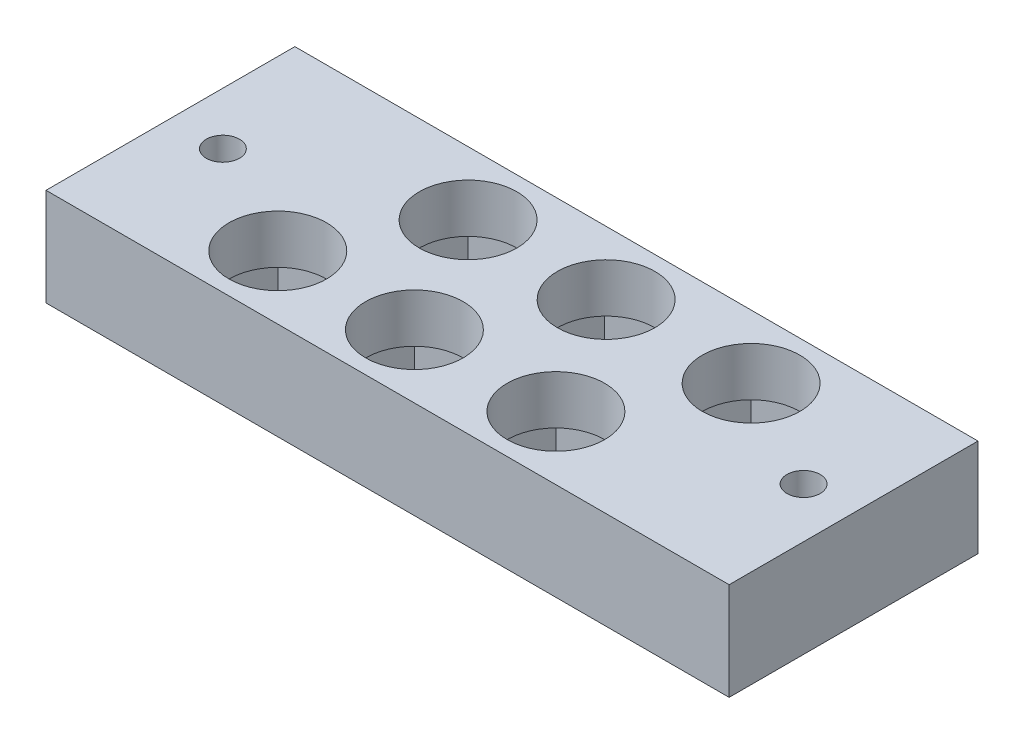
from build123d import *

# Parameters (mm, degrees)
SKETCH1_W           = 70
SKETCH1_H           = 25.5
SKETCH1_W_2         = 12
SKETCH1_H_2         = 12
SKETCH1_R           = 1.7
BOSS_EXTRUDE1_DEPTH = 10
SKETCH1_3_W         = 12
SKETCH1_3_H         = 12
SKETCH1_3_R         = 5
BOSS_EXTRUDE2_DEPTH = 5


with BuildPart() as part:
    # Sketch1 → Boss-Extrude1 (new body)
    with BuildSketch(Plane(origin=(0, 0, 0), x_dir=(1, 0, 0), z_dir=(0, 1, 0))):
        Rectangle(SKETCH1_W, SKETCH1_H)
        with Locations((-17.75, -6.25)):
            Rectangle(SKETCH1_W_2, SKETCH1_H_2, mode=Mode.SUBTRACT)
        with Locations((-29.625, 0)):
            Circle(SKETCH1_R, mode=Mode.SUBTRACT)
        with Locations((-3.75, -6.25)):
            Rectangle(SKETCH1_W_2, SKETCH1_H_2, mode=Mode.SUBTRACT)
        with Locations((10.75, -6.25)):
            Rectangle(SKETCH1_W_2, SKETCH1_H_2, mode=Mode.SUBTRACT)
        with Locations((29.875, 0)):
            Circle(SKETCH1_R, mode=Mode.SUBTRACT)
        with Locations((-10.75, 6.25)):
            Rectangle(SKETCH1_W_2, SKETCH1_H_2, mode=Mode.SUBTRACT)
        with Locations((3.25, 6.25)):
            Rectangle(SKETCH1_W_2, SKETCH1_H_2, mode=Mode.SUBTRACT)
        with Locations((18.25, 6.25)):
            Rectangle(SKETCH1_W_2, SKETCH1_H_2, mode=Mode.SUBTRACT)
    extrude(amount=-BOSS_EXTRUDE1_DEPTH)

    # Sketch1_3 → Boss-Extrude2 (add)
    # profile 1 of 6: a face of its own
    with BuildSketch(Plane(origin=(0, 0, 0), x_dir=(1, 0, 0), z_dir=(0, 1, 0))):
        with Locations((-17.75, -6.25)):
            Rectangle(SKETCH1_3_W, SKETCH1_3_H)
        with Locations((-17.75, -6.25)):
            Circle(SKETCH1_3_R, mode=Mode.SUBTRACT)
    # profile 2 of 6: a face of its own
    with BuildSketch(Plane(origin=(0, 0, 0), x_dir=(1, 0, 0), z_dir=(0, 1, 0))):
        with Locations((-3.75, -6.25)):
            Rectangle(SKETCH1_3_W, SKETCH1_3_H)
        with Locations((-3.75, -6.25)):
            Circle(SKETCH1_3_R, mode=Mode.SUBTRACT)
    # profile 3 of 6: a face of its own
    with BuildSketch(Plane(origin=(0, 0, 0), x_dir=(1, 0, 0), z_dir=(0, 1, 0))):
        with Locations((10.75, -6.25)):
            Rectangle(SKETCH1_3_W, SKETCH1_3_H)
        with Locations((10.75, -6.25)):
            Circle(SKETCH1_3_R, mode=Mode.SUBTRACT)
    # profile 4 of 6: a face of its own
    with BuildSketch(Plane(origin=(0, 0, 0), x_dir=(1, 0, 0), z_dir=(0, 1, 0))):
        with Locations((18.25, 6.25)):
            Rectangle(SKETCH1_3_W, SKETCH1_3_H)
        with Locations((18.25, 6.25)):
            Circle(SKETCH1_3_R, mode=Mode.SUBTRACT)
    # profile 5 of 6: a face of its own
    with BuildSketch(Plane(origin=(0, 0, 0), x_dir=(1, 0, 0), z_dir=(0, 1, 0))):
        with Locations((3.25, 6.25)):
            Rectangle(SKETCH1_3_W, SKETCH1_3_H)
        with Locations((3.394505145, 6.25)):
            Circle(SKETCH1_3_R, mode=Mode.SUBTRACT)
    # profile 6 of 6: a face of its own
    with BuildSketch(Plane(origin=(0, 0, 0), x_dir=(1, 0, 0), z_dir=(0, 1, 0))):
        with Locations((-10.75, 6.25)):
            Rectangle(SKETCH1_3_W, SKETCH1_3_H)
        with Locations((-10.75, 6.25)):
            Circle(SKETCH1_3_R, mode=Mode.SUBTRACT)
    extrude(amount=-BOSS_EXTRUDE2_DEPTH)


solid = part.part
